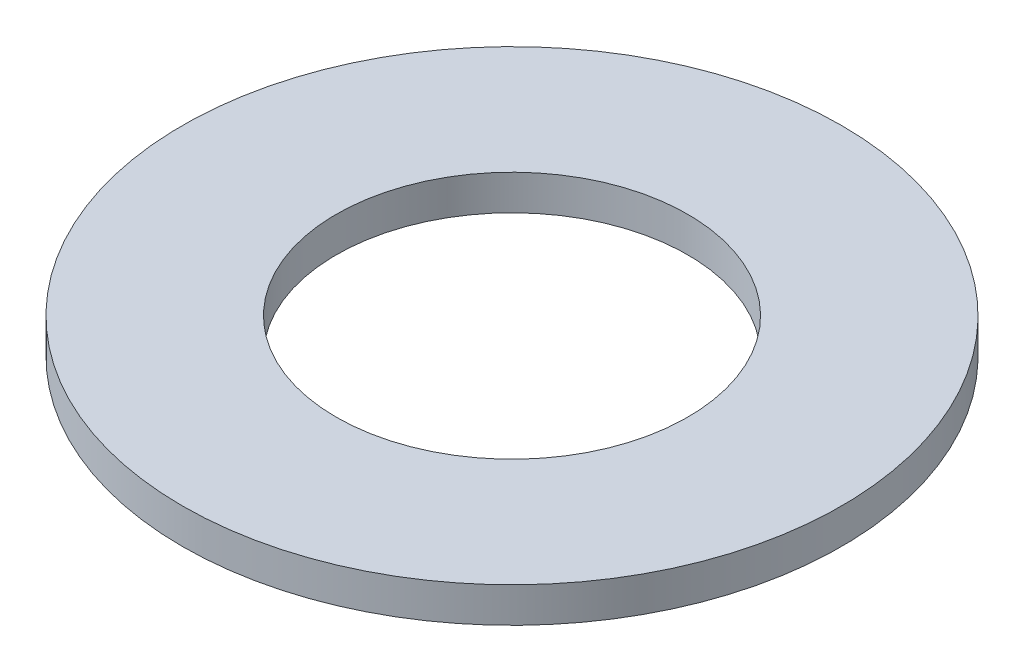
from build123d import *

# Parameters (mm, degrees)
SKETCH1_R           = 7.5
SKETCH1_R_2         = 4
BOSS_EXTRUDE1_DEPTH = 0.8


with BuildPart() as part:
    # Sketch1 → Boss-Extrude1 (new body)
    with BuildSketch(Plane(origin=(0, 0, 0), x_dir=(1, 0, 0), z_dir=(0, 1, 0))):
        Circle(SKETCH1_R)
        Circle(SKETCH1_R_2, mode=Mode.SUBTRACT)
    extrude(amount=BOSS_EXTRUDE1_DEPTH)


solid = part.part
